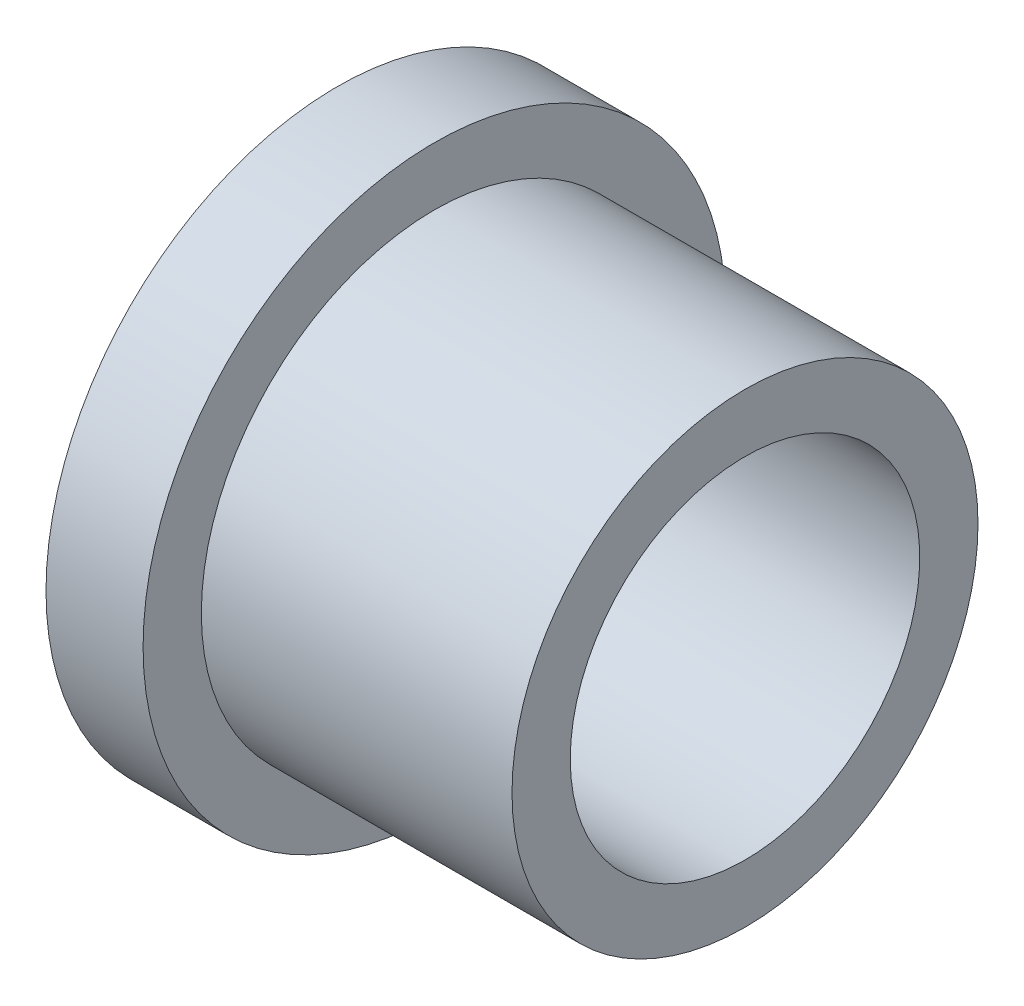
from build123d import *


with BuildPart() as part:
    # Sketch1 → Revolve1 (revolve)
    with BuildSketch(Plane.XY):
        Polygon((0, 9), (21, 9), (21, 12), (5, 12), (5, 15), (0, 15), align=None)
    revolve(axis=Axis((0, 0, 0), (1, 0, 0)))


solid = part.part
